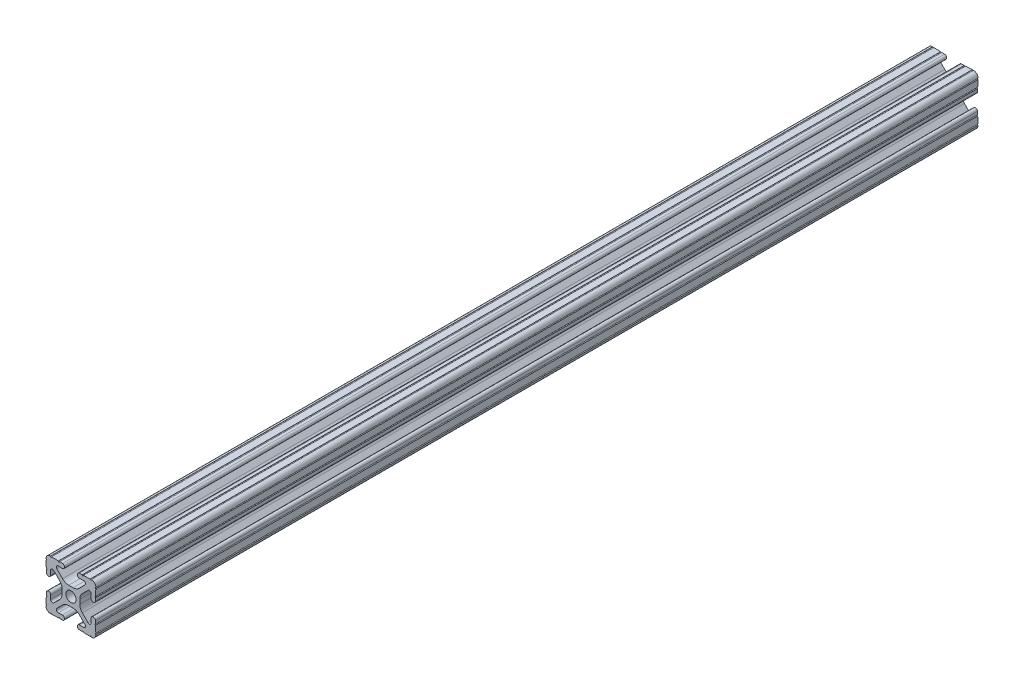
from build123d import *

# Parameters (mm, degrees)
SKETCH3_R               = 2.6035
EXTRUDE1_DEPTH          = 609.6
SKETCH5_W               = 49.363750246
SKETCH5_H               = 769.6
CUT_EXTRUDE1_DEPTH      = 10
CUT_EXTRUDE1_DEPTH_BACK = 60


with BuildPart() as part:
    # Sketch3 → Extrude1 (new body, symmetric)
    with BuildSketch(Plane.XY):
        with BuildLine():
            Line((-1.115277175, 4.5085), (1.115277175, 4.5085))
            ThreePointArc((1.115277175, 4.5085), (2.806584872, 4.844922018), (4.240406305, 5.80297087))
            Line((4.240406305, 5.80297087), (7.148423664, 8.710988229))
            ThreePointArc((7.148423664, 8.710988229), (7.349906316, 9.772227925), (6.436353897, 10.348636575))
            Line((6.436353897, 10.348636575), (4.381960454, 10.276895575))
            ThreePointArc((4.381960454, 10.276895575), (3.239173075, 11.342562046), (4.304839546, 12.485349424))
            Line((4.304839546, 12.485349424), (5.728246175, 12.535055879))
            ThreePointArc((5.728246175, 12.535055879), (6.054756855, 12.230579745), (6.35923299, 12.557090424))
            Line((6.35923299, 12.557090424), (9.782092278, 12.676619304))
            ThreePointArc((9.782092278, 12.676619304), (10.108602958, 12.37214317), (10.413079092, 12.69865385))
            ThreePointArc((10.413079092, 12.69865385), (12.052764565, 12.052764565), (12.69865385, 10.413079092))
            ThreePointArc((12.69865385, 10.413079092), (12.37214317, 10.108602958), (12.676619304, 9.782092278))
            Line((12.676619304, 9.782092278), (12.557090424, 6.35923299))
            ThreePointArc((12.557090424, 6.35923299), (12.230579745, 6.054756855), (12.535055879, 5.728246175))
            Line((12.535055879, 5.728246175), (12.485349424, 4.304839546))
            ThreePointArc((12.485349424, 4.304839546), (11.342562046, 3.239173075), (10.276895575, 4.381960454))
            Line((10.276895575, 4.381960454), (10.348636575, 6.436353897))
            ThreePointArc((10.348636575, 6.436353897), (9.772227925, 7.349906316), (8.710988229, 7.148423664))
            Line((8.710988229, 7.148423664), (5.80297087, 4.240406305))
            ThreePointArc((5.80297087, 4.240406305), (4.844922018, 2.806584872), (4.5085, 1.115277175))
            Line((4.5085, 1.115277175), (4.5085, -1.115277175))
            ThreePointArc((4.5085, -1.115277175), (4.844922018, -2.806584872), (5.80297087, -4.240406305))
            Line((5.80297087, -4.240406305), (8.710988229, -7.148423664))
            ThreePointArc((8.710988229, -7.148423664), (9.772227925, -7.349906316), (10.348636575, -6.436353897))
            Line((10.348636575, -6.436353897), (10.276895575, -4.381960454))
            ThreePointArc((10.276895575, -4.381960454), (11.342562046, -3.239173075), (12.485349424, -4.304839546))
            Line((12.485349424, -4.304839546), (12.535055879, -5.728246175))
            ThreePointArc((12.535055879, -5.728246175), (12.230579745, -6.054756855), (12.557090424, -6.35923299))
            Line((12.557090424, -6.35923299), (12.676619304, -9.782092278))
            ThreePointArc((12.676619304, -9.782092278), (12.37214317, -10.108602958), (12.69865385, -10.413079092))
            ThreePointArc((12.69865385, -10.413079092), (12.052764565, -12.052764565), (10.413079092, -12.69865385))
            ThreePointArc((10.413079092, -12.69865385), (10.108602958, -12.37214317), (9.782092278, -12.676619304))
            Line((9.782092278, -12.676619304), (6.35923299, -12.557090424))
            ThreePointArc((6.35923299, -12.557090424), (6.054756855, -12.230579745), (5.728246175, -12.535055879))
            Line((5.728246175, -12.535055879), (4.304839546, -12.485349424))
            ThreePointArc((4.304839546, -12.485349424), (3.239173075, -11.342562046), (4.381960454, -10.276895575))
            Line((4.381960454, -10.276895575), (6.436353897, -10.348636575))
            ThreePointArc((6.436353897, -10.348636575), (7.349906316, -9.772227925), (7.148423664, -8.710988229))
            Line((7.148423664, -8.710988229), (4.240406305, -5.80297087))
            ThreePointArc((4.240406305, -5.80297087), (2.806584872, -4.844922018), (1.115277175, -4.5085))
            Line((1.115277175, -4.5085), (-1.115277175, -4.5085))
            ThreePointArc((-1.115277175, -4.5085), (-2.806584872, -4.844922018), (-4.240406305, -5.80297087))
            Line((-4.240406305, -5.80297087), (-7.148423664, -8.710988229))
            ThreePointArc((-7.148423664, -8.710988229), (-7.349906316, -9.772227925), (-6.436353897, -10.348636575))
            Line((-6.436353897, -10.348636575), (-4.381960454, -10.276895575))
            ThreePointArc((-4.381960454, -10.276895575), (-3.239173075, -11.342562046), (-4.304839546, -12.485349424))
            Line((-4.304839546, -12.485349424), (-5.728246175, -12.535055879))
            ThreePointArc((-5.728246175, -12.535055879), (-6.054756855, -12.230579745), (-6.35923299, -12.557090424))
            Line((-6.35923299, -12.557090424), (-9.782092278, -12.676619304))
            ThreePointArc((-9.782092278, -12.676619304), (-10.108602958, -12.37214317), (-10.413079092, -12.69865385))
            ThreePointArc((-10.413079092, -12.69865385), (-12.052764565, -12.052764565), (-12.69865385, -10.413079092))
            ThreePointArc((-12.69865385, -10.413079092), (-12.37214317, -10.108602958), (-12.676619304, -9.782092278))
            Line((-12.676619304, -9.782092278), (-12.557090424, -6.35923299))
            ThreePointArc((-12.557090424, -6.35923299), (-12.230579745, -6.054756855), (-12.535055879, -5.728246175))
            Line((-12.535055879, -5.728246175), (-12.485349424, -4.304839546))
            ThreePointArc((-12.485349424, -4.304839546), (-11.342562046, -3.239173075), (-10.276895575, -4.381960454))
            Line((-10.276895575, -4.381960454), (-10.348636575, -6.436353897))
            ThreePointArc((-10.348636575, -6.436353897), (-9.772227925, -7.349906316), (-8.710988229, -7.148423664))
            Line((-8.710988229, -7.148423664), (-5.80297087, -4.240406305))
            ThreePointArc((-5.80297087, -4.240406305), (-4.844922018, -2.806584872), (-4.5085, -1.115277175))
            Line((-4.5085, -1.115277175), (-4.5085, 1.115277175))
            ThreePointArc((-4.5085, 1.115277175), (-4.844922018, 2.806584872), (-5.80297087, 4.240406305))
            Line((-5.80297087, 4.240406305), (-8.710988229, 7.148423664))
            ThreePointArc((-8.710988229, 7.148423664), (-9.772227925, 7.349906316), (-10.348636575, 6.436353897))
            Line((-10.348636575, 6.436353897), (-10.276895575, 4.381960454))
            ThreePointArc((-10.276895575, 4.381960454), (-11.342562046, 3.239173075), (-12.485349424, 4.304839546))
            Line((-12.485349424, 4.304839546), (-12.535055879, 5.728246175))
            ThreePointArc((-12.535055879, 5.728246175), (-12.230579745, 6.054756855), (-12.557090424, 6.35923299))
            Line((-12.557090424, 6.35923299), (-12.676619304, 9.782092278))
            ThreePointArc((-12.676619304, 9.782092278), (-12.37214317, 10.108602958), (-12.69865385, 10.413079092))
            ThreePointArc((-12.69865385, 10.413079092), (-12.052764565, 12.052764565), (-10.413079092, 12.69865385))
            ThreePointArc((-10.413079092, 12.69865385), (-10.108602958, 12.37214317), (-9.782092278, 12.676619304))
            Line((-9.782092278, 12.676619304), (-6.35923299, 12.557090424))
            ThreePointArc((-6.35923299, 12.557090424), (-6.054756855, 12.230579745), (-5.728246175, 12.535055879))
            Line((-5.728246175, 12.535055879), (-4.304839546, 12.485349424))
            ThreePointArc((-4.304839546, 12.485349424), (-3.239173075, 11.342562046), (-4.381960454, 10.276895575))
            Line((-4.381960454, 10.276895575), (-6.436353897, 10.348636575))
            ThreePointArc((-6.436353897, 10.348636575), (-7.349906316, 9.772227925), (-7.148423664, 8.710988229))
            Line((-7.148423664, 8.710988229), (-4.240406305, 5.80297087))
            ThreePointArc((-4.240406305, 5.80297087), (-2.806584872, 4.844922018), (-1.115277175, 4.5085))
        make_face()
        Circle(SKETCH3_R, mode=Mode.SUBTRACT)
    extrude(amount=EXTRUDE1_DEPTH, both=True)

    # Sketch5 → Cut-Extrude1 (cut, two sides)
    with BuildSketch(Plane(origin=(-0.430223788, 12.319997369, 0), x_dir=(0.999390827, 0.034899497, 0), z_dir=(-0.034899497, 0.999390827, 0))) as cut_extrude1_sk:
        with Locations((3.430761539, 224.8)):
            Rectangle(SKETCH5_W, SKETCH5_H)
    extrude(amount=CUT_EXTRUDE1_DEPTH, mode=Mode.SUBTRACT)
    extrude(cut_extrude1_sk.sketch, amount=-CUT_EXTRUDE1_DEPTH_BACK, mode=Mode.SUBTRACT)


solid = part.part
